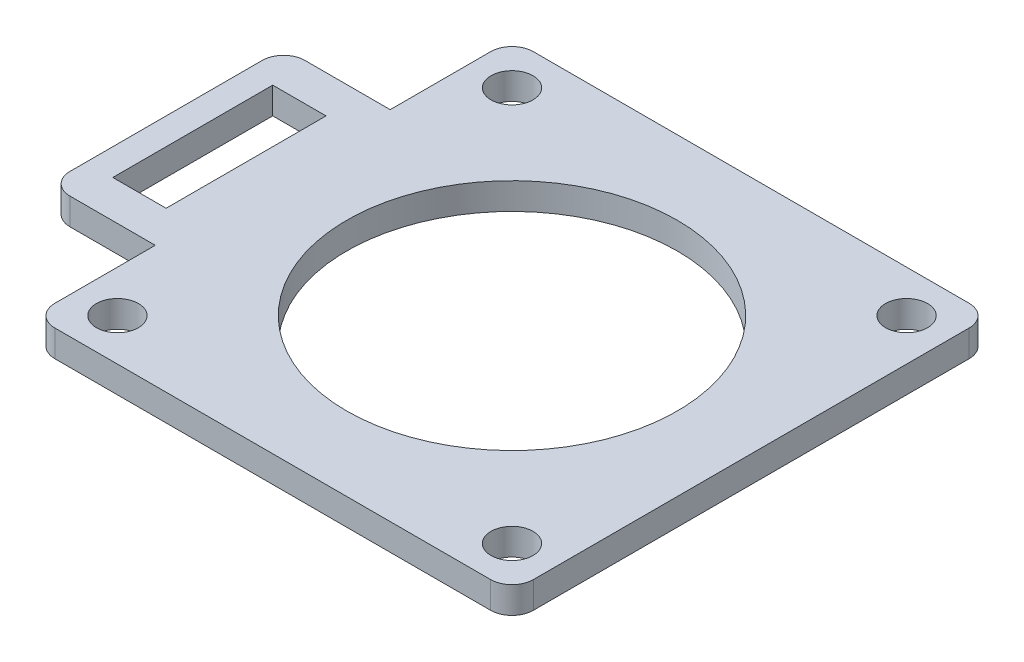
from build123d import *

# Parameters (mm, degrees)
SKETCH1_R           = 19.685
SKETCH1_R_2         = 2.499995
SKETCH1_W           = 6.35
SKETCH1_H           = 19.05
BOSS_EXTRUDE1_DEPTH = 3.175


with BuildPart() as part:
    # Sketch1 → Boss-Extrude1 (new body)
    with BuildSketch(Plane(origin=(0, 0, 0), x_dir=(1, 0, 0), z_dir=(0, 1, 0))):
        with BuildLine():
            Line((-13.993314597, 28.4999938), (-25.9599938, 28.4999938))
            ThreePointArc((-25.9599938, 28.4999938), (-27.756045024, 27.756045024), (-28.4999938, 25.9599938))
            Line((-28.4999938, 25.9599938), (-28.4999938, 13.993314597))
            Line((-28.4999938, 13.993314597), (-38.6599938, 13.993314597))
            ThreePointArc((-38.6599938, 13.993314597), (-40.456045024, 13.249365821), (-41.1999938, 11.453314597))
            Line((-41.1999938, 11.453314597), (-41.1999938, -11.453314597))
            ThreePointArc((-41.1999938, -11.453314597), (-40.456045024, -13.249365821), (-38.6599938, -13.993314597))
            Line((-38.6599938, -13.993314597), (-28.4999938, -13.993314597))
            Line((-28.4999938, -13.993314597), (-28.4999938, -25.9599938))
            ThreePointArc((-28.4999938, -25.9599938), (-27.756045024, -27.756045024), (-25.9599938, -28.4999938))
            Line((-25.9599938, -28.4999938), (-13.993314597, -28.4999938))
            Line((-13.993314597, -28.4999938), (13.993314597, -28.4999938))
            Line((13.993314597, -28.4999938), (25.9599938, -28.4999938))
            ThreePointArc((25.9599938, -28.4999938), (27.756045024, -27.756045024), (28.4999938, -25.9599938))
            Line((28.4999938, -25.9599938), (28.4999938, -13.993314597))
            Line((28.4999938, -13.993314597), (28.4999938, 13.993314597))
            Line((28.4999938, 13.993314597), (28.4999938, 25.9599938))
            ThreePointArc((28.4999938, 25.9599938), (27.756045024, 27.756045024), (25.9599938, 28.4999938))
            Line((25.9599938, 28.4999938), (13.993314597, 28.4999938))
            Line((13.993314597, 28.4999938), (-13.993314597, 28.4999938))
        make_face()
        Circle(SKETCH1_R, mode=Mode.SUBTRACT)
        with Locations((-23.5000038, 23.5000038)):
            Circle(SKETCH1_R_2, mode=Mode.SUBTRACT)
        with Locations((23.5000038, 23.5000038)):
            Circle(SKETCH1_R_2, mode=Mode.SUBTRACT)
        with Locations((23.5000038, -23.5000038)):
            Circle(SKETCH1_R_2, mode=Mode.SUBTRACT)
        with Locations((-23.5000038, -23.5000038)):
            Circle(SKETCH1_R_2, mode=Mode.SUBTRACT)
        with Locations((-34.8499938, 0)):
            Rectangle(SKETCH1_W, SKETCH1_H, mode=Mode.SUBTRACT)
    extrude(amount=BOSS_EXTRUDE1_DEPTH)


solid = part.part
